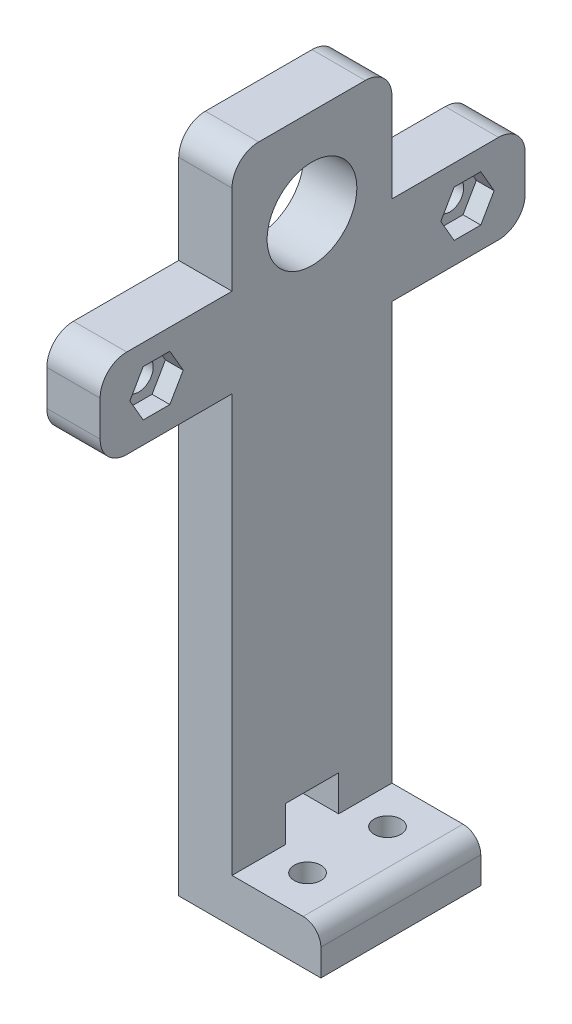
from build123d import *

# Parameters (mm, degrees)
SKETCH1_R                 = 17.45
SKETCH1_R_2               = 12.45
BOSS_EXTRUDE1_DEPTH       = 8
SKETCH2_R                 = 20
SKETCH2_R_2               = 12.45
BOSS_EXTRUDE2_DEPTH       = 2
SKETCH3_R                 = 32.5
SKETCH3_R_2               = 12.45
BOSS_EXTRUDE3_DEPTH       = 4
FILLET1_R                 = 1
BOSS_EXTRUDE6_START       = -4
SKETCH10_W                = 10
SKETCH10_H                = 18
BOSS_EXTRUDE6_DEPTH       = 4
SKETCH4_W                 = 6
SKETCH4_H                 = 18
BOSS_EXTRUDE4_DEPTH       = 75
BOSS_EXTRUDE4_DEPTH_BACK  = 4
SKETCH5_R                 = 5.05
CUT_EXTRUDE1_DEPTH        = 306
CUT_EXTRUDE1_DEPTH_BACK   = 113
SKETCH6_W                 = 6
SKETCH6_H                 = 10
BOSS_EXTRUDE5_DEPTH       = 15
BOSS_EXTRUDE5_DEPTH_BACK  = 32.85
SKETCH7_R                 = 1.629220746
SKETCH7_R_2               = 1.580258945
CUT_EXTRUDE2_DEPTH        = 10
SKETCH9_R                 = 5.05
CUT_EXTRUDE3_DEPTH        = 10
CUT_EXTRUDE3_DEPTH_BACK   = 10
SKETCH11_W                = 9.782596874
SKETCH11_H                = 3.234517514
CUT_EXTRUDE4_DEPTH        = 123
CUT_EXTRUDE4_DEPTH_BACK   = 61
FILLET4_R                 = 3
FILLET5_R                 = 3
SKETCH12_W                = 108.791398151
SKETCH12_H                = 24.041848298
CUT_EXTRUDE5_DEPTH        = 110.678
SKETCH15_R                = 22
CUT_EXTRUDE7_DEPTH        = 4
SKETCH13_R                = 22
SKETCH13_R_2              = 11
SKETCH13_R_3              = 2.75
BOSS_EXTRUDE7_DEPTH       = 4
FILLET6_R                 = 3
CUT_EXTRUDE8_DEPTH        = 5
FILLET7_R                 = 1
BOSS_EXTRUDE8_START       = -3
BOSS_EXTRUDE8_DEPTH       = 9.4
FILLET8_R                 = 3
FILLET8_OF_MIRROR2_R      = 3
CUT_EXTRUDE12_START       = -6
SKETCH21_R                = 6.05
CUT_EXTRUDE12_DEPTH       = 3.8
SKETCH18_W                = 88.746975794
SKETCH18_H                = 20.386854219
CUT_EXTRUDE9_DEPTH        = 10
SKETCH19_W                = 6
SKETCH19_H                = 10.45
BOSS_EXTRUDE9_DEPTH       = 5
FILLET9_R                 = 2
CUT_EXTRUDE13_DEPTH       = 2
SKETCH23_R                = 1
CUT_EXTRUDE14_DEPTH       = 11
CUT_EXTRUDE16_DEPTH       = 1.7
CUT_EXTRUDE17_DEPTH       = 30
CUT_EXTRUDE17_DEPTH_BACK  = 70
SKETCH27_W                = 18
SKETCH27_H                = 5
BOSS_EXTRUDE10_DEPTH      = 10
BOSS_EXTRUDE10_DEPTH_BACK = 6
FILLET10_R                = 2
SKETCH28_W                = 6
SKETCH28_H                = 4
CUT_EXTRUDE18_DEPTH       = 10
SKETCH29_R                = 1.5
CUT_EXTRUDE19_DEPTH       = 100


with BuildPart() as part:
    # Sketch1 → Boss-Extrude1 (new body)
    with BuildSketch(Plane(origin=(0, 0, 0), x_dir=(1, 0, 0), z_dir=(0, 1, 0))):
        Circle(SKETCH1_R)
        Circle(SKETCH1_R_2, mode=Mode.SUBTRACT)
    extrude(amount=BOSS_EXTRUDE1_DEPTH)

    # Sketch2 → Boss-Extrude2 (add)
    with BuildSketch(Plane(origin=(0, 8, 0), x_dir=(1, 0, 0), z_dir=(0, 1, 0))):
        Circle(SKETCH2_R)
        Circle(SKETCH2_R_2, mode=Mode.SUBTRACT)
    extrude(amount=BOSS_EXTRUDE2_DEPTH)

    # Sketch3 → Boss-Extrude3 (add)
    with BuildSketch(Plane(origin=(0, 10, 0), x_dir=(1, 0, 0), z_dir=(0, 1, 0))):
        Circle(SKETCH3_R)
        Circle(SKETCH3_R_2, mode=Mode.SUBTRACT)
    extrude(amount=BOSS_EXTRUDE3_DEPTH)

    # Fillet1
    fillet1_edges = [part.edges().sort_by_distance(p)[0] for p in [
        (-32.5, 14, 0),
    ]]
    fillet(fillet1_edges, radius=FILLET1_R)

    # Sketch10 → Boss-Extrude6 (add)
    with BuildSketch(Plane(origin=(0, 14, 0), x_dir=(1, 0, 0), z_dir=(0, 1, 0)).offset(BOSS_EXTRUDE6_START)):
        with Locations((35.186917696, 0)):
            Rectangle(SKETCH10_W, SKETCH10_H)
        with Locations((-35.186917696, 0)):
            Rectangle(SKETCH10_W, SKETCH10_H)
    extrude(amount=BOSS_EXTRUDE6_DEPTH)

    # Sketch4 → Boss-Extrude4 (add, two sides)
    with BuildSketch(Plane(origin=(0, 14, 0), x_dir=(1, 0, 0), z_dir=(0, 1, 0))) as boss_extrude4_sk:
        with Locations((-37.186917696, 0)):
            Rectangle(SKETCH4_W, SKETCH4_H)
        with Locations((37.186917696, 0)):
            Rectangle(SKETCH4_W, SKETCH4_H)
    extrude(amount=BOSS_EXTRUDE4_DEPTH)
    extrude(boss_extrude4_sk.sketch, amount=-BOSS_EXTRUDE4_DEPTH_BACK)

    # Sketch5 → Cut-Extrude1 (cut, two sides)
    with BuildSketch(Plane.ZY.offset(-34.186917696)) as cut_extrude1_sk:
        with Locations((0, 79)):
            Circle(SKETCH5_R)
    extrude(amount=CUT_EXTRUDE1_DEPTH, mode=Mode.SUBTRACT)
    extrude(cut_extrude1_sk.sketch, amount=-CUT_EXTRUDE1_DEPTH_BACK, mode=Mode.SUBTRACT)

    # Sketch6 → Boss-Extrude5 (add, two sides)
    with BuildSketch(Plane(origin=(0, 0, -9), x_dir=(-1, 0, 0), z_dir=(0, 0, -1))) as boss_extrude5_sk:
        with Locations((37.186917696, 70.95)):
            Rectangle(SKETCH6_W, SKETCH6_H)
    extrude(amount=BOSS_EXTRUDE5_DEPTH)
    extrude(boss_extrude5_sk.sketch, amount=-BOSS_EXTRUDE5_DEPTH_BACK)

    # Sketch7 → Cut-Extrude2 (cut)
    with BuildSketch(Plane(origin=(-34.186917696, 0, 0), x_dir=(0, 0, -1), z_dir=(1, 0, 0))):
        with Locations((-17.5, 71)):
            Circle(SKETCH7_R)
        with Locations((17.5, 71)):
            Circle(SKETCH7_R_2)
    extrude(amount=-CUT_EXTRUDE2_DEPTH, mode=Mode.SUBTRACT)

    # Sketch9 → Cut-Extrude3 (cut, two sides)
    with BuildSketch(Plane(origin=(-34.186917696, 0, 0), x_dir=(0, 0, -1), z_dir=(1, 0, 0))) as cut_extrude3_sk:
        with Locations((0, 79)):
            Circle(SKETCH9_R)
    extrude(amount=CUT_EXTRUDE3_DEPTH, mode=Mode.SUBTRACT)
    extrude(cut_extrude3_sk.sketch, amount=-CUT_EXTRUDE3_DEPTH_BACK, mode=Mode.SUBTRACT)

    # Sketch11 → Cut-Extrude4 (cut, two sides)
    with BuildSketch(Plane.ZY.offset(-34.186917696)) as cut_extrude4_sk:
        with Locations((0, 15.617258757)):
            Rectangle(SKETCH11_W, SKETCH11_H)
    extrude(amount=CUT_EXTRUDE4_DEPTH, mode=Mode.SUBTRACT)
    extrude(cut_extrude4_sk.sketch, amount=-CUT_EXTRUDE4_DEPTH_BACK, mode=Mode.SUBTRACT)

    # Fillet4
    fillet4_edges = [part.edges().sort_by_distance(p)[0] for p in [
        (-37.186917696, 65.95, 23.85),
        (-37.186917696, 75.95, 23.85),
        (-37.186917696, 65.95, -24),
        (-37.186917696, 75.95, -24),
        (-37.186917696, 89, -9),
        (-37.186917696, 89, 9),
    ]]
    fillet(fillet4_edges, radius=FILLET4_R)

    # Fillet5
    fillet5_edges = [part.edges().sort_by_distance(p)[0] for p in [
        (40.186917696, 10, 0),
        (-40.186917696, 10, 0),
    ]]
    fillet(fillet5_edges, radius=FILLET5_R)

    # Sketch12 → Cut-Extrude5 (cut)
    with BuildSketch(Plane(origin=(40.186917696, 0, 0), x_dir=(0, 0, -1), z_dir=(1, 0, 0))):
        with Locations((-12.502918017, -2.020924149)):
            Rectangle(SKETCH12_W, SKETCH12_H)
    extrude(amount=-CUT_EXTRUDE5_DEPTH, mode=Mode.SUBTRACT)

    # Sketch15 → Cut-Extrude7 (cut)
    with BuildSketch(Plane(origin=(0, 14, 0), x_dir=(1, 0, 0), z_dir=(0, 1, 0))):
        Circle(SKETCH15_R)
    extrude(amount=-CUT_EXTRUDE7_DEPTH, mode=Mode.SUBTRACT)

    # Sketch13 → Boss-Extrude7 (add)
    with BuildSketch(Plane(origin=(0, 14, 0), x_dir=(1, 0, 0), z_dir=(0, 1, 0))):
        Circle(SKETCH13_R)
        Circle(SKETCH13_R_2, mode=Mode.SUBTRACT)
        with Locations((0, 17.5)):
            Circle(SKETCH13_R_3, mode=Mode.SUBTRACT)
        with Locations((-15.155444566, -8.75)):
            Circle(SKETCH13_R_3, mode=Mode.SUBTRACT)
        with Locations((15.155444566, -8.75)):
            Circle(SKETCH13_R_3, mode=Mode.SUBTRACT)
    extrude(amount=-BOSS_EXTRUDE7_DEPTH)

    # Fillet6
    fillet6_edges = [part.edges().sort_by_distance(p)[0] for p in [
        (37.186917696, 89, 9),
        (37.186917696, 89, -9),
    ]]
    fillet(fillet6_edges, radius=FILLET6_R)

    # Sketch16 → Cut-Extrude8 (cut)
    with BuildSketch(Plane.XZ.offset(-10)):
        with BuildLine():
            Line((-31.228992939, 9), (-20.29384143, 9))
            ThreePointArc((-20.29384143, 9), (0, 22.2), (20.29384143, 9))
            Line((20.29384143, 9), (31.228992939, 9))
            ThreePointArc((31.228992939, 9), (0, 32.5), (-31.228992939, 9))
        make_face()
    cut_extrude8 = extrude(amount=-CUT_EXTRUDE8_DEPTH, mode=Mode.SUBTRACT)

    # Mirror1: Cut-Extrude8 across plane
    add(cut_extrude8.mirror(Plane.XY), mode=Mode.SUBTRACT)

    # Fillet7
    fillet7_edges = [part.edges().sort_by_distance(p)[0] for p in [
        (0, 14, 22.2),
        (0, 14, -22.2),
    ]]
    fillet(fillet7_edges, radius=FILLET7_R)

    # Sketch17 → Boss-Extrude8 (add)
    with BuildSketch(Plane.XZ.offset(-10).offset(BOSS_EXTRUDE8_START)):
        with BuildLine():
            Line((20.29384143, -9), (40.186917696, -9))
            Line((40.186917696, -9), (40.186917696, 9))
            Line((40.186917696, 9), (20.29384143, 9))
            ThreePointArc((20.29384143, 9), (22.2, 0), (20.29384143, -9))
        make_face()
    boss_extrude8 = extrude(amount=BOSS_EXTRUDE8_DEPTH)

    # Fillet8
    fillet8_edges = [part.edges().sort_by_distance(p)[0] for p in [
        (40.186917696, 3.6, 0),
    ]]
    fillet(fillet8_edges, radius=FILLET8_R)

    # Mirror2: Boss-Extrude8 across plane
    add(boss_extrude8.mirror(Plane(origin=(0, 0, 0), x_dir=(0, 0, 1), z_dir=(1, 0, 0))))

    # Fillet8 of Mirror2
    fillet8_of_mirror2_edges = [part.edges().sort_by_distance(p)[0] for p in [
        (-40.186917696, 3.6, 0),
    ]]
    fillet(fillet8_of_mirror2_edges, radius=FILLET8_OF_MIRROR2_R)

    # Sketch21 → Cut-Extrude12 (cut)
    with BuildSketch(Plane(origin=(40.186917696, 0, 0), x_dir=(0, 0, -1), z_dir=(1, 0, 0)).offset(CUT_EXTRUDE12_START)):
        with Locations((0, 79)):
            Circle(SKETCH21_R)
    extrude(amount=CUT_EXTRUDE12_DEPTH, mode=Mode.SUBTRACT)

    # Sketch18 → Cut-Extrude9 (cut)
    with BuildSketch(Plane(origin=(40.186917696, 0, 0), x_dir=(0, 0, -1), z_dir=(1, 0, 0))):
        with Locations((0, 89.193427109)):
            Rectangle(SKETCH18_W, SKETCH18_H)
    extrude(amount=-CUT_EXTRUDE9_DEPTH, mode=Mode.SUBTRACT)

    # Sketch19 → Boss-Extrude9 (add)
    with BuildSketch(Plane(origin=(0, 79, 0), x_dir=(1, 0, 0), z_dir=(0, 1, 0))):
        with Locations((37.186917696, -11.275)):
            Rectangle(SKETCH19_W, SKETCH19_H)
        with Locations((37.186917696, 11.275)):
            Rectangle(SKETCH19_W, SKETCH19_H)
    extrude(amount=-BOSS_EXTRUDE9_DEPTH)

    # Fillet9
    fillet9_edges = [part.edges().sort_by_distance(p)[0] for p in [
        (37.186917696, 74, 16.5),
        (37.186917696, 74, -16.5),
    ]]
    fillet(fillet9_edges, radius=FILLET9_R)

    # Sketch22 → Cut-Extrude13 (cut)
    with BuildSketch(Plane(origin=(-34.186917696, 0, 0), x_dir=(0, 0, -1), z_dir=(1, 0, 0))):
        Polygon((-15.9988893, 68.4), (-14.4977786, 71), (-15.9988893, 73.6), (-19.0011107, 73.6), (-20.5022214, 71), (-19.0011107, 68.4), align=None)
        Polygon((20.5022214, 71), (19.0011107, 73.6), (15.9988893, 73.6), (14.4977786, 71), (15.9988893, 68.4), (19.0011107, 68.4), align=None)
    extrude(amount=-CUT_EXTRUDE13_DEPTH, mode=Mode.SUBTRACT)

    # Sketch23 → Cut-Extrude14 (cut)
    with BuildSketch(Plane(origin=(0, 79, 0), x_dir=(1, 0, 0), z_dir=(0, 1, 0))):
        with Locations((37.186917696, -12.3)):
            Circle(SKETCH23_R)
        with Locations((37.186917696, 12.3)):
            Circle(SKETCH23_R)
    extrude(amount=-CUT_EXTRUDE14_DEPTH, mode=Mode.SUBTRACT)

    # Sketch24 → Cut-Extrude16 (cut)
    with BuildSketch(Plane.XZ.offset(-74)):
        Polygon((37.186917696, 9.990598923), (39.186917696, 11.145299462), (39.186917696, 13.454700538), (37.186917696, 14.609401077), (35.186917696, 13.454700538), (35.186917696, 11.145299462), align=None)
        Polygon((37.186917696, -14.609401077), (39.186917696, -13.454700538), (39.186917696, -11.145299462), (37.186917696, -9.990598923), (35.186917696, -11.145299462), (35.186917696, -13.454700538), align=None)
    extrude(amount=-CUT_EXTRUDE16_DEPTH, mode=Mode.SUBTRACT)

    # Sketch26 → Cut-Extrude17 (cut, two sides)
    with BuildSketch(Plane(origin=(0, 0, -9), x_dir=(-1, 0, 0), z_dir=(0, 0, -1))) as cut_extrude17_sk:
        Polygon((34.186917696, 14), (34.186917696, 94.491380316), (-54.251567272, 94.491380316), (-54.251567272, -8.918618382), (55.508733715, -8.918618382), (55.508733715, 14), align=None)
    extrude(amount=CUT_EXTRUDE17_DEPTH, mode=Mode.SUBTRACT)
    extrude(cut_extrude17_sk.sketch, amount=-CUT_EXTRUDE17_DEPTH_BACK, mode=Mode.SUBTRACT)

    # Sketch27 → Boss-Extrude10 (add, two sides)
    with BuildSketch(Plane(origin=(-34.186917696, 0, 0), x_dir=(0, 0, -1), z_dir=(1, 0, 0))) as boss_extrude10_sk:
        with Locations((0, 16.5)):
            Rectangle(SKETCH27_W, SKETCH27_H)
    extrude(amount=BOSS_EXTRUDE10_DEPTH)
    extrude(boss_extrude10_sk.sketch, amount=-BOSS_EXTRUDE10_DEPTH_BACK)

    # Fillet10
    fillet10_edges = [part.edges().sort_by_distance(p)[0] for p in [
        (-24.186917696, 19, 0),
    ]]
    fillet(fillet10_edges, radius=FILLET10_R)

    # Sketch28 → Cut-Extrude18 (cut)
    with BuildSketch(Plane(origin=(-34.186917696, 0, 0), x_dir=(0, 0, -1), z_dir=(1, 0, 0))):
        with Locations((0, 21)):
            Rectangle(SKETCH28_W, SKETCH28_H)
    extrude(amount=-CUT_EXTRUDE18_DEPTH, mode=Mode.SUBTRACT)

    # Sketch29 → Cut-Extrude19 (cut)
    with BuildSketch(Plane(origin=(0, 19, 0), x_dir=(1, 0, 0), z_dir=(0, 1, 0))):
        with Locations((-30.186917696, -4.5)):
            Circle(SKETCH29_R)
        with Locations((-30.186917696, 4.5)):
            Circle(SKETCH29_R)
    extrude(amount=-CUT_EXTRUDE19_DEPTH, mode=Mode.SUBTRACT)


solid = part.part
